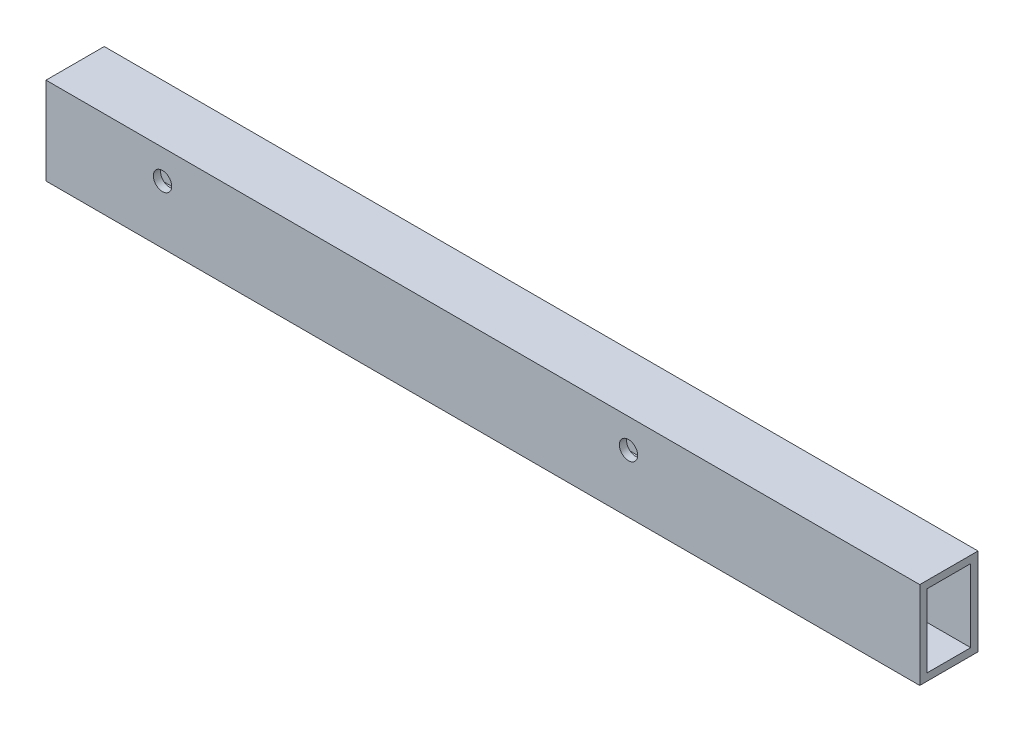
from build123d import *

# Parameters (mm, degrees)
SKETCH1_W           = 25.4
SKETCH1_H           = 38.1
SKETCH1_W_2         = 19.05
SKETCH1_H_2         = 31.75
BOSS_EXTRUDE1_DEPTH = 381
SKETCH2_R           = 4
CUT_EXTRUDE1_DEPTH  = 26.4


with BuildPart() as part:
    # Sketch1 → Boss-Extrude1 (new body)
    with BuildSketch(Plane(origin=(0, 0, 0), x_dir=(0, 0, -1), z_dir=(1, 0, 0))):
        Rectangle(SKETCH1_W, SKETCH1_H)
        Rectangle(SKETCH1_W_2, SKETCH1_H_2, mode=Mode.SUBTRACT)
    extrude(amount=BOSS_EXTRUDE1_DEPTH)

    # Sketch2 → Cut-Extrude1 (cut, through all)
    with BuildSketch(Plane(origin=(0, 0, -12.7), x_dir=(-1, 0, 0), z_dir=(0, 0, -1))):
        with Locations((-50.8, 6.35)):
            Circle(SKETCH2_R)
        with Locations((-254, 6.35)):
            Circle(SKETCH2_R)
    extrude(amount=-CUT_EXTRUDE1_DEPTH, mode=Mode.SUBTRACT)


solid = part.part
